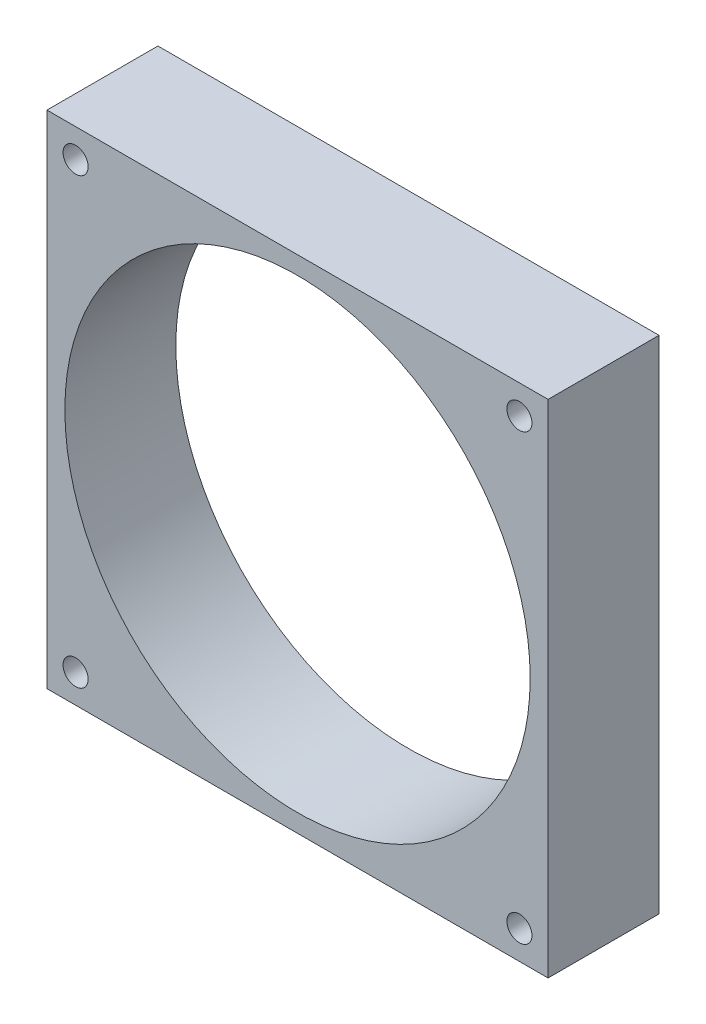
from build123d import *

# Parameters (mm, degrees)
ESBO_O1_W                = 70
ESBO_O1_H                = 70
ESBO_O1_R                = 1.75
ESBO_O1_R_2              = 32.5
RESSALTO_EXTRUS_O1_DEPTH = 15.5


with BuildPart() as part:
    # Esboço1 → Ressalto-extrusão1 (new body)
    with BuildSketch(Plane.XY):
        Rectangle(ESBO_O1_W, ESBO_O1_H)
        with Locations((-31, -31)):
            Circle(ESBO_O1_R, mode=Mode.SUBTRACT)
        with Locations((31, -31)):
            Circle(ESBO_O1_R, mode=Mode.SUBTRACT)
        with Locations((31, 31)):
            Circle(ESBO_O1_R, mode=Mode.SUBTRACT)
        Circle(ESBO_O1_R_2, mode=Mode.SUBTRACT)
        with Locations((-31, 31)):
            Circle(ESBO_O1_R, mode=Mode.SUBTRACT)
    extrude(amount=RESSALTO_EXTRUS_O1_DEPTH)


solid = part.part
